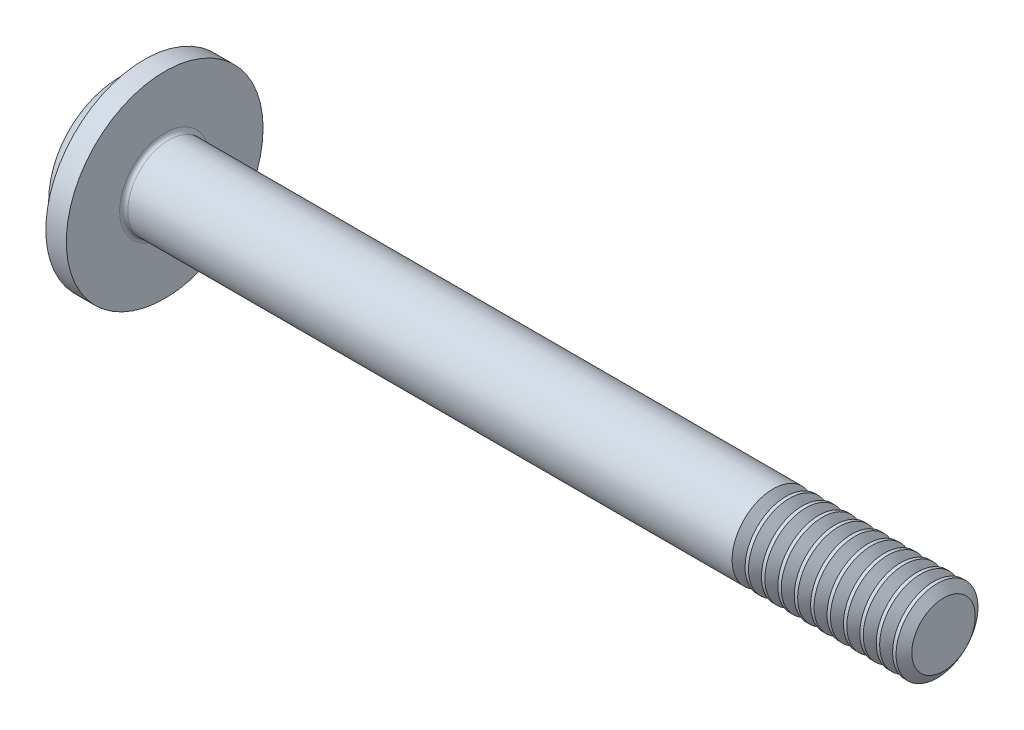
from build123d import *

# Parameters (mm, degrees)
FILLET1_R                = 0.1
SKETCH3_W                = 0.48
SKETCH3_H                = 2.1
SKETCH4_W                = 0.48
SKETCH4_H                = 0.68402847
RECPAT_COUNT             = 2
RECPAT_ANGLE             = 90
THDSCHPAT_COUNT          = 11
THDSCHPAT_PITCH          = 0.4
ESBO_O1_R                = 2.4
RESSALTO_EXTRUS_O1_DEPTH = 0.5


with BuildPart() as part:
    # BodySke → Base-Revolve (revolve)
    with BuildSketch(Plane.XY):
        with BuildLine():
            Line((1.6, 1), (1.6, 2))
            Line((1.6, 2), (1.1, 2))
            ThreePointArc((1.1, 2), (0.688403396, 1.885994341), (0.394117647, 1.576470588))
            ThreePointArc((0.394117647, 1.576470588), (0.100022625, 0.812494344), (0, 0))
            Line((0, 0), (20.6, 0))
            Line((20.6, 0), (20.6, 1))
            Line((20.6, 1), (1.6, 1))
        make_face()
    revolve(axis=Axis((-25.4, 0, 0), (1, 0, 0)))

    # Fillet1
    fillet1_edges = [part.edges().sort_by_distance(p)[0] for p in [
        (1.6, -1, 0),
    ]]
    fillet(fillet1_edges, radius=FILLET1_R)

    # Sketch3 → Recess section 0
    with BuildSketch(Plane(origin=(0, 0, 0), x_dir=(0, 0, -1), z_dir=(1, 0, 0))):
        Rectangle(SKETCH3_W, SKETCH3_H)
    # Sketch4 → Recess section 1
    with BuildSketch(Plane(origin=(1.42, 0, 0), x_dir=(0, 0, -1), z_dir=(1, 0, 0))):
        Rectangle(SKETCH4_W, SKETCH4_H)
    recess = loft(mode=Mode.SUBTRACT)

    # RecPat: Recess ×2 about axis
    recpat_axis = Axis((0, 0, 0), (1, 0, 0))
    for i in range(1, RECPAT_COUNT):
        add(recess.rotate(recpat_axis, i * RECPAT_ANGLE / (RECPAT_COUNT - 1)), mode=Mode.SUBTRACT)

    # RecCorSke → RecessCore (revolve, cut)
    with BuildSketch(Plane.XY):
        Polygon((0, 0), (0, 0.454796073), (1.42, 0.3555), (1.535508952, 0), align=None)
    revolve(axis=Axis((-3.175, 0, 0), (1, 0, 0)), mode=Mode.SUBTRACT)

    # ThdSchSke → ThreadSchematic (revolve, cut)
    with BuildSketch(Plane.XY):
        Polygon((16.6, -0.774), (16.441753096, -1), (16.441753096, -1.25), (16.758246904, -1.25), (16.758246904, -1), align=None)
    threadschematic = revolve(axis=Axis((-3.175, 0, 0), (1, 0, 0)), mode=Mode.SUBTRACT)

    # ThdSchPat: ThreadSchematic ×11
    with Locations(*[(i * THDSCHPAT_PITCH, 0, 0) for i in range(1, THDSCHPAT_COUNT)]):
        add(threadschematic, mode=Mode.SUBTRACT)

    # Esboço1 → Ressalto-extrusão1 (add)
    with BuildSketch(Plane(origin=(1.6, 0, 0), x_dir=(0, 0, -1), z_dir=(1, 0, 0))):
        Circle(ESBO_O1_R)
    extrude(amount=-RESSALTO_EXTRUS_O1_DEPTH)


solid = part.part
